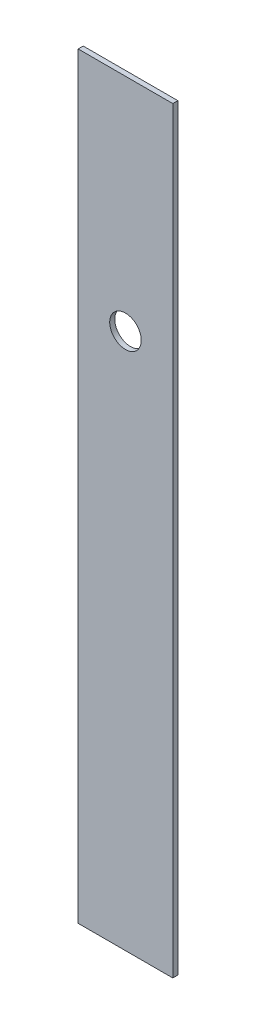
from build123d import *

# Parameters (mm, degrees)
SKETCH1_W           = 19.05
SKETCH1_H           = 152.4
BOSS_EXTRUDE1_DEPTH = 1.016
SKETCH2_R           = 3.175
CUT_EXTRUDE1_DEPTH  = 2.016


with BuildPart() as part:
    # Sketch1 → Boss-Extrude1 (new body)
    with BuildSketch(Plane.XY):
        with Locations((0, 76.2)):
            Rectangle(SKETCH1_W, SKETCH1_H)
    extrude(amount=BOSS_EXTRUDE1_DEPTH)

    # Sketch2 → Cut-Extrude1 (cut, through all)
    with BuildSketch(Plane.XY.offset(1.016)):
        with Locations((0, 107.95)):
            Circle(SKETCH2_R)
    extrude(amount=-CUT_EXTRUDE1_DEPTH, mode=Mode.SUBTRACT)


solid = part.part
